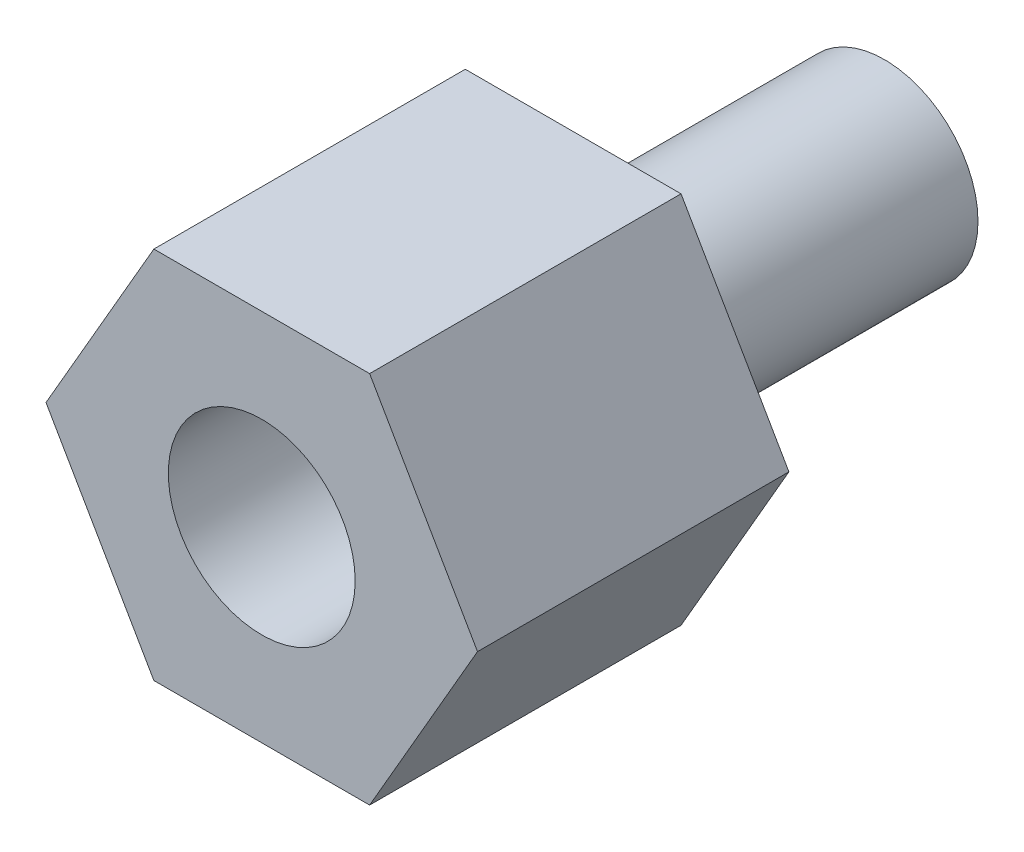
from build123d import *

# Parameters (mm, degrees)
SKETCH_1_R          = 1.5
EXTRUDE_1_DEPTH     = 5
EXTRUDE_2_DEPTH     = 5
SKETCH_3_R          = 1.5
CUT_EXTRUDE_1_DEPTH = 4


with BuildPart() as part:
    # Эскиз1 → Бобышка-Вытянуть1 (new body)
    with BuildSketch(Plane.XY):
        Circle(SKETCH_1_R)
    extrude(amount=EXTRUDE_1_DEPTH)

    # Эскиз2 → Бобышка-Вытянуть2 (add)
    with BuildSketch(Plane.XY.offset(5)):
        Polygon((-3.464101615, 0), (-1.732050808, -3), (1.732050808, -3), (3.464101615, 0), (1.732050808, 3), (-1.732050808, 3), align=None)
    extrude(amount=EXTRUDE_2_DEPTH)

    # Эскиз3 → Вырез-Вытянуть1 (cut)
    with BuildSketch(Plane.XY.offset(10)):
        Circle(SKETCH_3_R)
    extrude(amount=-CUT_EXTRUDE_1_DEPTH, mode=Mode.SUBTRACT)


solid = part.part
